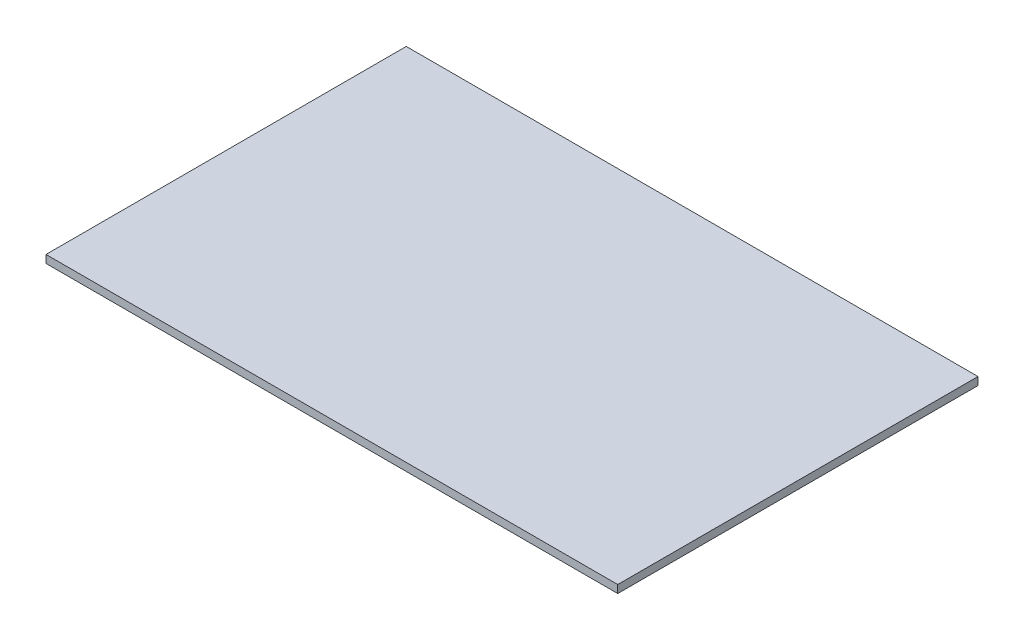
from build123d import *

# Parameters (mm, degrees)
CROQUIS1_W              = 73
CROQUIS1_H              = 46
SALIENTE_EXTRUIR1_DEPTH = 1


with BuildPart() as part:
    # Croquis1 → Saliente-Extruir1 (new body)
    with BuildSketch(Plane(origin=(0, 0, 0), x_dir=(1, 0, 0), z_dir=(0, 1, 0))):
        Rectangle(CROQUIS1_W, CROQUIS1_H)
    extrude(amount=SALIENTE_EXTRUIR1_DEPTH)


solid = part.part
